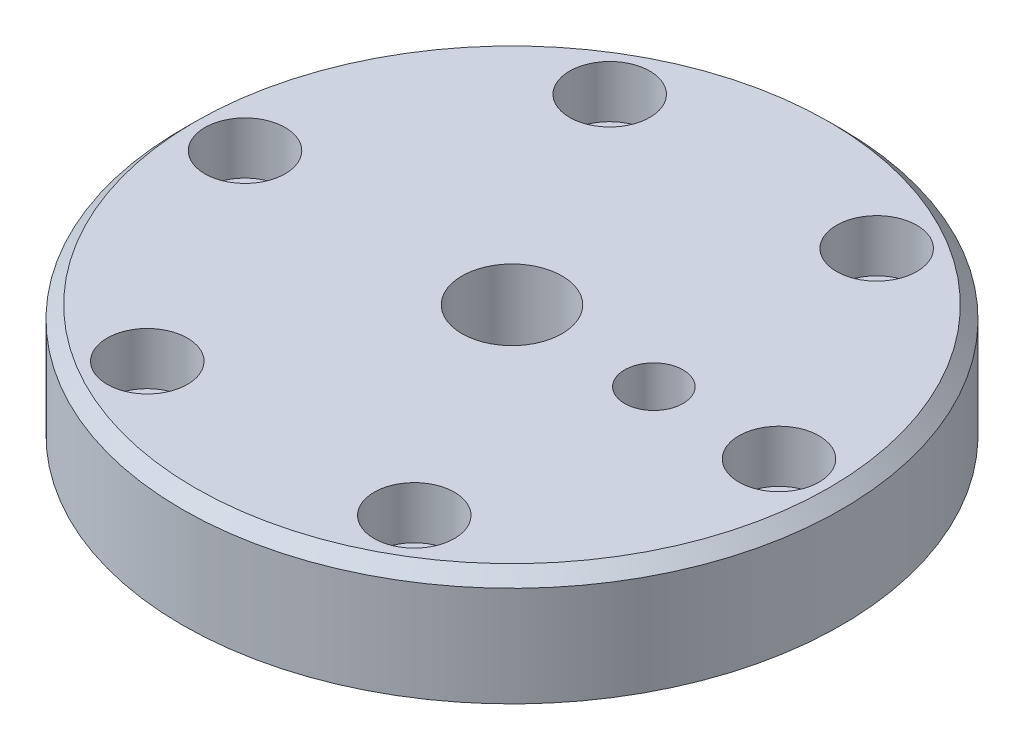
from build123d import *

# Parameters (mm, degrees)
SKETCH1_R                               = 79
SKETCH1_R_2                             = 12
BOSS_EXTRUDE1_DEPTH                     = 27
CBORE_FOR_M5_HEX_HEAD_BOLT6_D           = 12.5
CBORE_FOR_M5_HEX_HEAD_BOLT6_CBORE_D     = 19.25
CBORE_FOR_M5_HEX_HEAD_BOLT6_CBORE_DEPTH = 12.5
CIRPATTERN1_COUNT                       = 6
F_1_0MM_DOWEL_HOLE1_D                   = 14
F_1_0MM_DOWEL_HOLE1_DEPTH               = 17
F_1_0MM_DOWEL_HOLE1_TIP                 = 4.206024333
SKETCH20_R                              = 33
SKETCH20_R_2                            = 22
CUT_EXTRUDE1_DEPTH                      = 6
CHAMFER1_SIZE                           = 3


with BuildPart() as part:
    # Sketch1 → Boss-Extrude1 (new body)
    with BuildSketch(Plane(origin=(0, 0, 0), x_dir=(1, 0, 0), z_dir=(0, 1, 0))):
        Circle(SKETCH1_R)
        Circle(SKETCH1_R_2, mode=Mode.SUBTRACT)
    extrude(amount=BOSS_EXTRUDE1_DEPTH)

    # CBORE for M5 Hex Head Bolt6 (through all)
    with Locations(Plane(origin=(0, 27, 0), x_dir=(1, 0, 0), z_dir=(0, 1, 0))):
        with Locations((32, 55.425625842)):
            cbore_for_m5_hex_head_bolt6 = CounterBoreHole(CBORE_FOR_M5_HEX_HEAD_BOLT6_D / 2, CBORE_FOR_M5_HEX_HEAD_BOLT6_CBORE_D / 2, CBORE_FOR_M5_HEX_HEAD_BOLT6_CBORE_DEPTH)

    # CirPattern1: CBORE for M5 Hex Head Bolt6 ×6 about axis
    cirpattern1_axis = Axis((0, 0, 0), (0, 1, 0))
    for i in range(1, CIRPATTERN1_COUNT):
        add(cbore_for_m5_hex_head_bolt6.rotate(cirpattern1_axis, i * 360 / CIRPATTERN1_COUNT), mode=Mode.SUBTRACT)

    # Ø1.0mm Dowel Hole1
    with Locations(Plane(origin=(0, 27, 0), x_dir=(1, 0, 0), z_dir=(0, 1, 0))):
        with Locations((34, 0)):
            Hole(F_1_0MM_DOWEL_HOLE1_D / 2, depth=F_1_0MM_DOWEL_HOLE1_DEPTH)
            with Locations((0, 0, -(F_1_0MM_DOWEL_HOLE1_DEPTH + F_1_0MM_DOWEL_HOLE1_TIP / 2))):  # 118° drill point
                Cone(0, F_1_0MM_DOWEL_HOLE1_D / 2, F_1_0MM_DOWEL_HOLE1_TIP, mode=Mode.SUBTRACT)

    # Sketch20 → Cut-Extrude1 (cut)
    with BuildSketch(Plane(origin=(0, 0, 0), x_dir=(1, 0, 0), z_dir=(0, 1, 0))):
        Circle(SKETCH20_R)
        Circle(SKETCH20_R_2, mode=Mode.SUBTRACT)
    extrude(amount=CUT_EXTRUDE1_DEPTH, mode=Mode.SUBTRACT)

    # Chamfer1
    chamfer1_edges = [part.edges().sort_by_distance(p)[0] for p in [
        (-79, 27, 0),
    ]]
    chamfer(chamfer1_edges, length=CHAMFER1_SIZE)


solid = part.part
